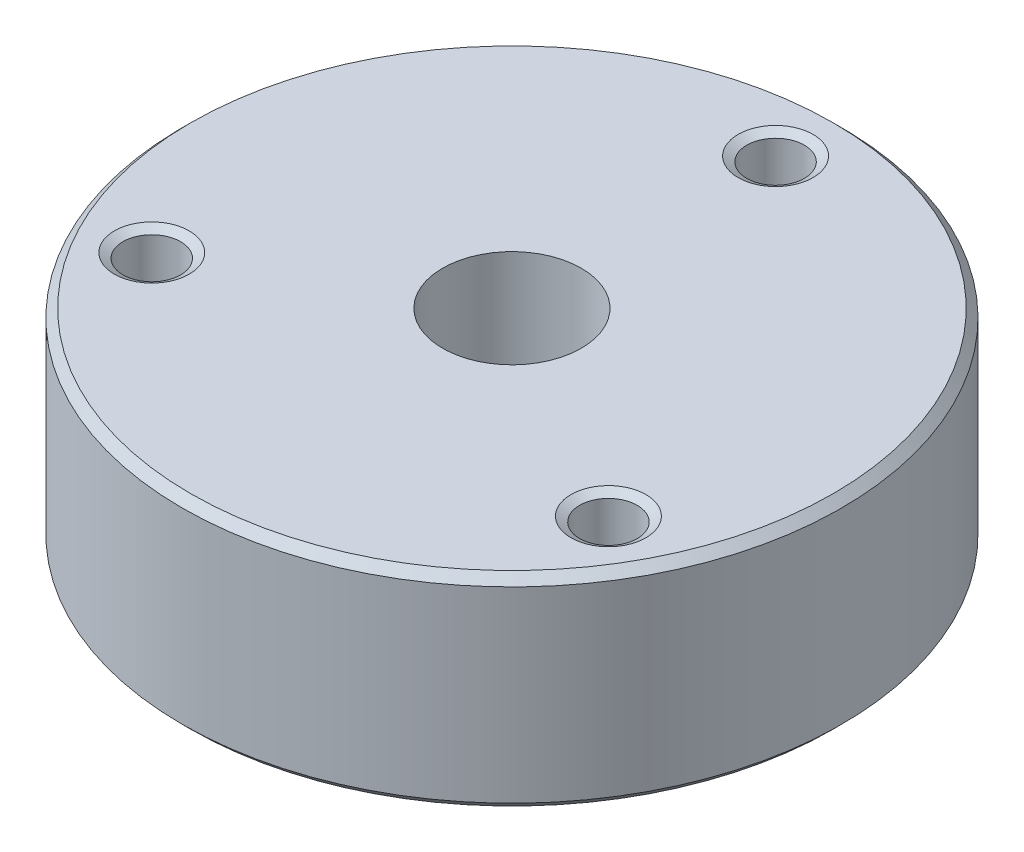
from build123d import *

# Parameters (mm, degrees)
SKETCH1_R                            = 30.1625
EXTRUDE1_DEPTH                       = 9.3345
CIRPATTERN1_COUNT                    = 3
F_1_2_0_5_DIAMETER_HOLE1_D           = 12.69746
F_1_2_0_5_DIAMETER_HOLE1_CSINK_D     = 14.224
F_1_2_0_5_DIAMETER_HOLE1_CSINK_ANGLE = 90
CHAMFER1_SIZE                        = 0.762
F_1_2_0_5_DIAMETER_HOLE2_D           = 12.7254
F_1_2_0_5_DIAMETER_HOLE2_DEPTH       = 3.175
F_1_2_0_5_DIAMETER_HOLE2_TIP         = 3.823095861


with BuildPart() as part:
    # Sketch1 → Extrude1 (new body, symmetric)
    with BuildSketch(Plane(origin=(0, 0, 0), x_dir=(1, 0, 0), z_dir=(0, 1, 0))):
        with Locations(Location((0, 0, 0), (0, 0, 270))):  # turned: the seam where the file's is
            Circle(SKETCH1_R)
    extrude(amount=EXTRUDE1_DEPTH, both=True)

    # Sketch2 → Tapped Hole for _8-32 Helicoil1 (revolve, cut)
    with BuildSketch(Plane(origin=(0, 9.3345, -24.13), x_dir=(0, 0, 1), z_dir=(1, 0, 0))):
        Polygon((0, 0), (0, 18.669), (2.1971, 18.669), (2.1971, 10.3632), (2.63779, 10.3632), (2.63779, 0.456805306), (3.429, 0), align=None)
    tapped_hole_for_8_32_helicoil1 = revolve(axis=Axis((0, 15.6845, -24.13), (0, -1, 0)), mode=Mode.SUBTRACT)

    # CirPattern1: Tapped Hole for _8-32 Helicoil1 ×3 about axis
    cirpattern1_axis = Axis((0, 0, 0), (0, 1, 0))
    for i in range(1, CIRPATTERN1_COUNT):
        add(tapped_hole_for_8_32_helicoil1.rotate(cirpattern1_axis, i * 360 / CIRPATTERN1_COUNT), mode=Mode.SUBTRACT)

    # 1_2 _0.5_ Diameter Hole1 (through all)
    with Locations(Plane(origin=(-26.174612808, -9.3345, 9.244261036), x_dir=(1, 0, 0), z_dir=(0, -1, 0))):
        with Locations((26.174612808, -9.244261036)):
            CounterSinkHole(F_1_2_0_5_DIAMETER_HOLE1_D / 2, F_1_2_0_5_DIAMETER_HOLE1_CSINK_D / 2, counter_sink_angle=F_1_2_0_5_DIAMETER_HOLE1_CSINK_ANGLE)

    # Chamfer1
    chamfer1_edges = [part.edges().sort_by_distance(p)[0] for p in [
        (0, -9.3345, -30.1625),
        (0, 9.3345, -30.1625),
    ]]
    chamfer(chamfer1_edges, length=CHAMFER1_SIZE)

    # 1_2 _0.5_ Diameter Hole2
    with Locations(Plane.XZ.offset(9.3345)):
        with Locations((0, 0)):
            Hole(F_1_2_0_5_DIAMETER_HOLE2_D / 2, depth=F_1_2_0_5_DIAMETER_HOLE2_DEPTH)
            with Locations((0, 0, -(F_1_2_0_5_DIAMETER_HOLE2_DEPTH + F_1_2_0_5_DIAMETER_HOLE2_TIP / 2))):  # 118° drill point
                Cone(0, F_1_2_0_5_DIAMETER_HOLE2_D / 2, F_1_2_0_5_DIAMETER_HOLE2_TIP, mode=Mode.SUBTRACT)


solid = part.part
